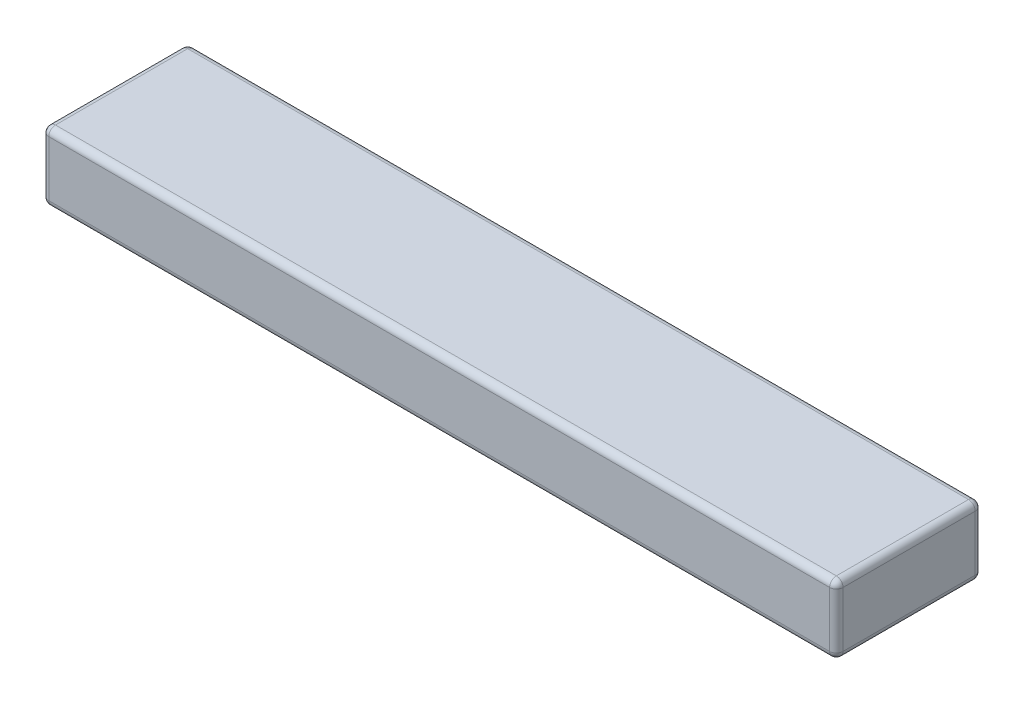
from build123d import *

# Parameters (mm, degrees)
SKETCH1_W           = 300
SKETCH1_H           = 55
BOSS_EXTRUDE1_DEPTH = 26
FILLET1_R           = 2.54


with BuildPart() as part:
    # Sketch1 → Boss-Extrude1 (new body)
    with BuildSketch(Plane(origin=(0, 0, 0), x_dir=(1, 0, 0), z_dir=(0, 1, 0))):
        Rectangle(SKETCH1_W, SKETCH1_H)
    extrude(amount=BOSS_EXTRUDE1_DEPTH)

    # Fillet1
    fillet1_edges = [part.edges().sort_by_distance(p)[0] for p in [
        (150, 26, 0),
        (0, 26, -27.5),
        (-150, 26, 0),
        (0, 0, -27.5),
        (150, 0, 0),
        (0, 0, 27.5),
        (-150, 0, 0),
        (0, 26, 27.5),
        (-150, 13, -27.5),
        (150, 13, -27.5),
        (150, 13, 27.5),
        (-150, 13, 27.5),
    ]]
    fillet(fillet1_edges, radius=FILLET1_R)


solid = part.part
